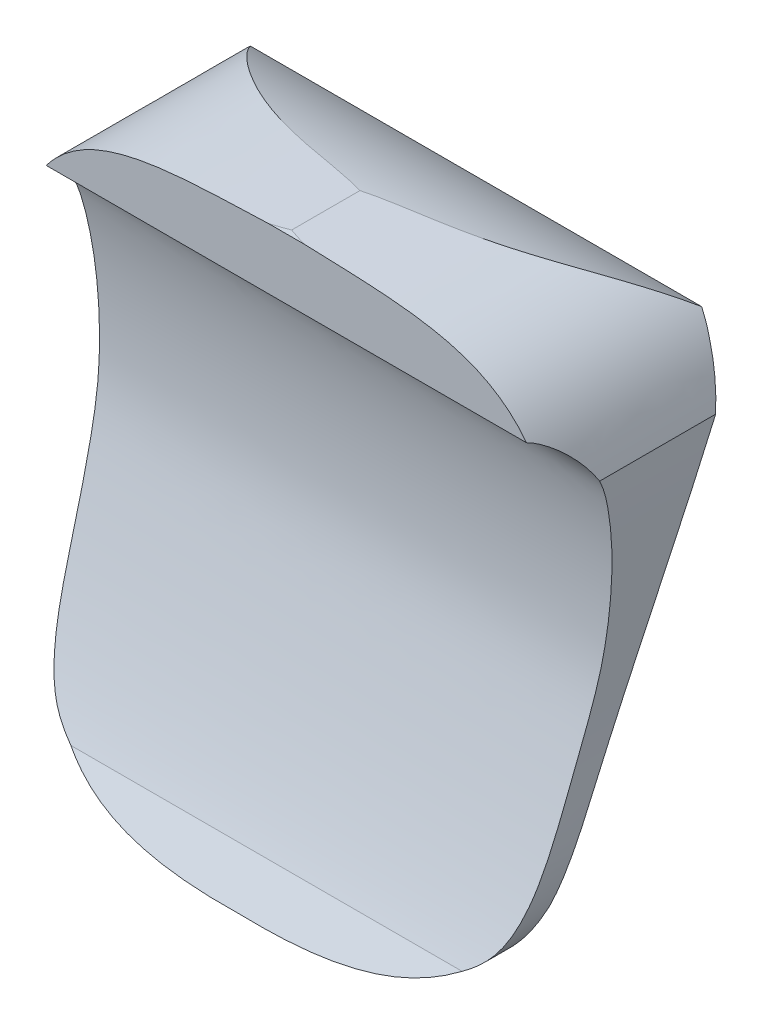
from build123d import *

# Parameters (mm, degrees)
SKETCH2_W                = 220
SKETCH2_H                = 220
BOSS_EXTRUDE1_DEPTH      = 4
BOSS_EXTRUDE2_DEPTH      = 130
BOSS_EXTRUDE2_DEPTH_BACK = 130
SKETCH6_W                = 271.253474956
SKETCH6_H                = 451.136798236
CUT_EXTRUDE3_DEPTH       = 142.630485135
CUT_EXTRUDE3_DEPTH_BACK  = 21.125925117


with BuildPart() as part:
    # Sketch2 → Boss-Extrude1 (new body)
    with BuildSketch(Plane(origin=(0, 6.368129006, 17.496290649), x_dir=(-1, 0, 0), z_dir=(0, 0.342020143, 0.939692621))):
        Rectangle(SKETCH2_W, SKETCH2_H)
    extrude(amount=BOSS_EXTRUDE1_DEPTH)

    # Sketch4 → Boss-Extrude2 (add, two sides)
    with BuildSketch(Plane(origin=(0, 0, 0), x_dir=(0, 0, -1), z_dir=(1, 0, 0))) as boss_extrude2_sk:
        with BuildLine():
            Line((-73.153859422, -124.738628786), (-58.877276898, -95.629978707))
            Line((-58.877276898, -95.629978707), (16.367154634, 111.102397866))
            Line((16.367154634, 111.102397866), (20.044894991, 119.64393668))
            add(Edge.make_bspline(
                [(-73.491417624, 141.830560189), (-21.838651032, 148.90043739), (20.044894991, 119.64393668)],
                knots=[0, 0, 0, 1, 1, 1], degree=2))
            Line((-73.491417624, 141.830560189), (-73.491417624, 111.830560189))
            add(Edge.make_bspline(
                [(-83.287166414, -120.061717866), (-70.702863199, -92.795727567), (-48.770285373, -25.902055591), (-38.710529927, 12.549262392), (-39.623408568, 59.810081458), (-50.04349951, 96.04705901), (-64.900243893, 108.790606408), (-73.491417624, 111.830560189)],
                knots=[0, 0, 0, 0, 0.291321016, 0.538048373, 0.793152384, 0.839347547, 1, 1, 1, 1], degree=3))
            Line((-83.287166414, -120.061717866), (-141.630485035, -207.383304545))
            Line((-141.630485035, -207.383304545), (-116.624314208, -218.924614157))
            Line((-116.624314208, -218.924614157), (-73.153859422, -124.738628786))
        make_face()
    extrude(amount=BOSS_EXTRUDE2_DEPTH)
    extrude(boss_extrude2_sk.sketch, amount=-BOSS_EXTRUDE2_DEPTH_BACK)

    # Sketch6 → Cut-Extrude3 (cut, two sides)
    with BuildSketch(Plane.XY) as cut_extrude3_sk:
        Rectangle(SKETCH6_W, SKETCH6_H)
        with BuildLine():
            add(Edge.make_bspline(
                [(0, 142.166059655), (64.72985929, 139.510930195), (112.530336934, 142.695135129), (130, 88.92836321)],
                knots=[0, 0, 0, 0, 1, 1, 1, 1], degree=3))
            add(Edge.make_bspline(
                [(130, 88.92836321), (127.790766755, 44.563627031), (121.320382637, -17.156230693), (118.605466608, -103.008260782), (79.508620128, -134.276844251), (41.11365207, -138.872289274), (0, -138.317729945)],
                knots=[0, 0, 0, 0, 0.431823514, 0.636023475, 0.692841124, 1, 1, 1, 1], degree=3))
            add(Edge.make_bspline(
                [(-130, 88.92836321), (-127.790766755, 44.563627031), (-121.320382637, -17.156230693), (-118.605466608, -103.008260782), (-79.508620128, -134.276844251), (-41.11365207, -138.872289274), (0, -138.317729945)],
                knots=[0, 0, 0, 0, 0.431823514, 0.636023475, 0.692841124, 1, 1, 1, 1], degree=3))
            add(Edge.make_bspline(
                [(0, 142.166059655), (-64.72985929, 139.510930195), (-112.530336934, 142.695135129), (-130, 88.92836321)],
                knots=[0, 0, 0, 0, 1, 1, 1, 1], degree=3))
        make_face(mode=Mode.SUBTRACT)
    extrude(amount=CUT_EXTRUDE3_DEPTH, mode=Mode.SUBTRACT)
    extrude(cut_extrude3_sk.sketch, amount=-CUT_EXTRUDE3_DEPTH_BACK, mode=Mode.SUBTRACT)


solid = part.part
